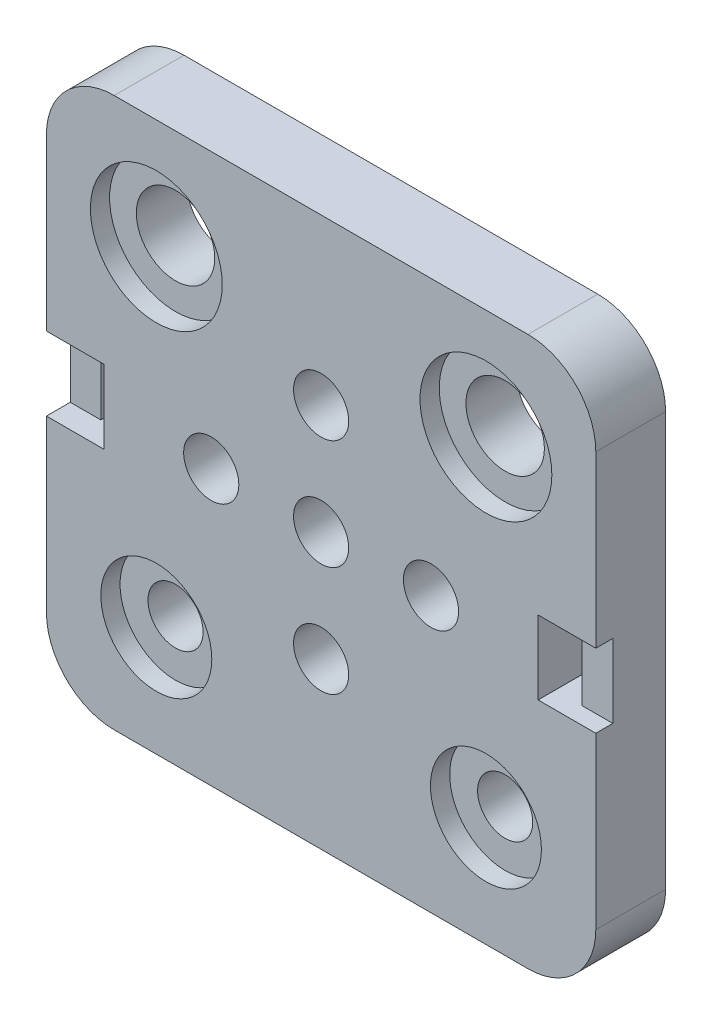
from build123d import *

# Parameters (mm, degrees)
SKETCH1_W           = 50
SKETCH1_H           = 50
SKETCH1_R           = 3.57
SKETCH1_R_2         = 2.51
BOSS_EXTRUDE1_DEPTH = 6.35
SKETCH2_R           = 6
SKETCH2_R_2         = 5.05
CUT_EXTRUDE1_DEPTH  = 1.75
SKETCH3_W           = 5.25
SKETCH3_H           = 6.7
CUT_EXTRUDE2_DEPTH  = 7
SKETCH4_W           = 2.785
SKETCH4_H           = 4.18
SKETCH4_W_2         = 2.79
SKETCH4_H_2         = 4.8
BOSS_EXTRUDE3_DEPTH = 6.7
FILLET1_R           = 6.17


with BuildPart() as part:
    # Sketch1 → Boss-Extrude1 (new body)
    with BuildSketch(Plane.XY):
        Rectangle(SKETCH1_W, SKETCH1_H)
        with Locations((-15, 15)):
            Circle(SKETCH1_R, mode=Mode.SUBTRACT)
        with Locations((15, 15)):
            Circle(SKETCH1_R, mode=Mode.SUBTRACT)
        with Locations((15, -15)):
            Circle(SKETCH1_R_2, mode=Mode.SUBTRACT)
        with Locations((-15, -15)):
            Circle(SKETCH1_R_2, mode=Mode.SUBTRACT)
        with Locations((-10, 0)):
            Circle(SKETCH1_R_2, mode=Mode.SUBTRACT)
        with Locations((0, 10)):
            Circle(SKETCH1_R_2, mode=Mode.SUBTRACT)
        with Locations((10, 0)):
            Circle(SKETCH1_R_2, mode=Mode.SUBTRACT)
        with Locations((0, -10)):
            Circle(SKETCH1_R_2, mode=Mode.SUBTRACT)
        Circle(SKETCH1_R_2, mode=Mode.SUBTRACT)
    extrude(amount=BOSS_EXTRUDE1_DEPTH)

    # Sketch2 → Cut-Extrude1 (cut)
    with BuildSketch(Plane.XY.offset(6.35)):
        with Locations((-15, 15)):
            Circle(SKETCH2_R)
        with Locations((15, 15)):
            Circle(SKETCH2_R)
        with Locations((-15, -15)):
            Circle(SKETCH2_R_2)
        with Locations((15, -15)):
            Circle(SKETCH2_R_2)
    extrude(amount=-CUT_EXTRUDE1_DEPTH, mode=Mode.SUBTRACT)

    # Sketch3 → Cut-Extrude2 (cut)
    with BuildSketch(Plane.XY.offset(6.35)):
        with Locations((-22.375, 0)):
            Rectangle(SKETCH3_W, SKETCH3_H)
        with Locations((22.375, 0)):
            Rectangle(SKETCH3_W, SKETCH3_H)
    extrude(amount=-CUT_EXTRUDE2_DEPTH, mode=Mode.SUBTRACT)

    # Sketch4 → Boss-Extrude3 (add)
    with BuildSketch(Plane.XZ.offset(-3.35)):
        with Locations((-23.6075, 2.09)):
            Rectangle(SKETCH4_W, SKETCH4_H)
        with Locations((23.605, 2.4)):
            Rectangle(SKETCH4_W_2, SKETCH4_H_2)
    extrude(amount=BOSS_EXTRUDE3_DEPTH)

    # Fillet1
    fillet1_edges = [part.edges().sort_by_distance(p)[0] for p in [
        (25, -25, 3.175),
        (-25, -25, 3.175),
        (-25, 25, 3.175),
        (25, 25, 3.175),
    ]]
    fillet(fillet1_edges, radius=FILLET1_R)


solid = part.part
